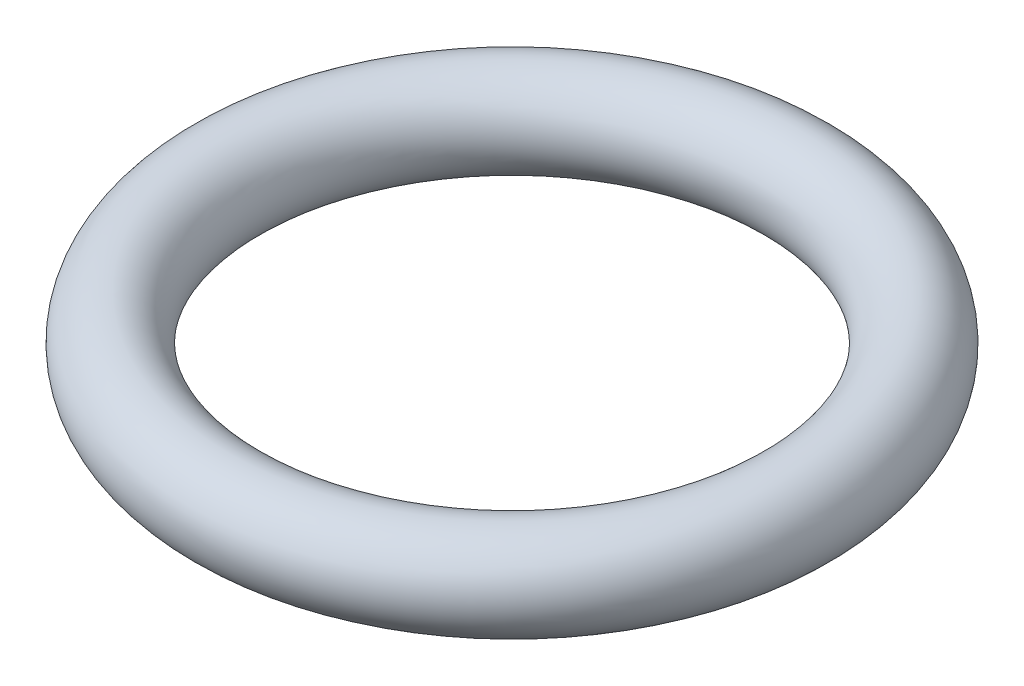
from build123d import *

# Parameters (mm, degrees)
SKETCH2_R = 1.2


with BuildPart() as part:
    # Sweep1: sweep along a path in Sketch1
    with BuildLine(Plane(origin=(0, 0, 0), x_dir=(1, 0, 0), z_dir=(0, 1, 0))) as sweep1_path:
        CenterArc((0, 0), 6.3, 0, 360)
    # Sketch2 → Sweep1 (sweep)
    with BuildSketch(Plane.XY):
        with Locations((-7.5, 0)):
            Circle(SKETCH2_R)
    sweep(path=sweep1_path.line)


solid = part.part
